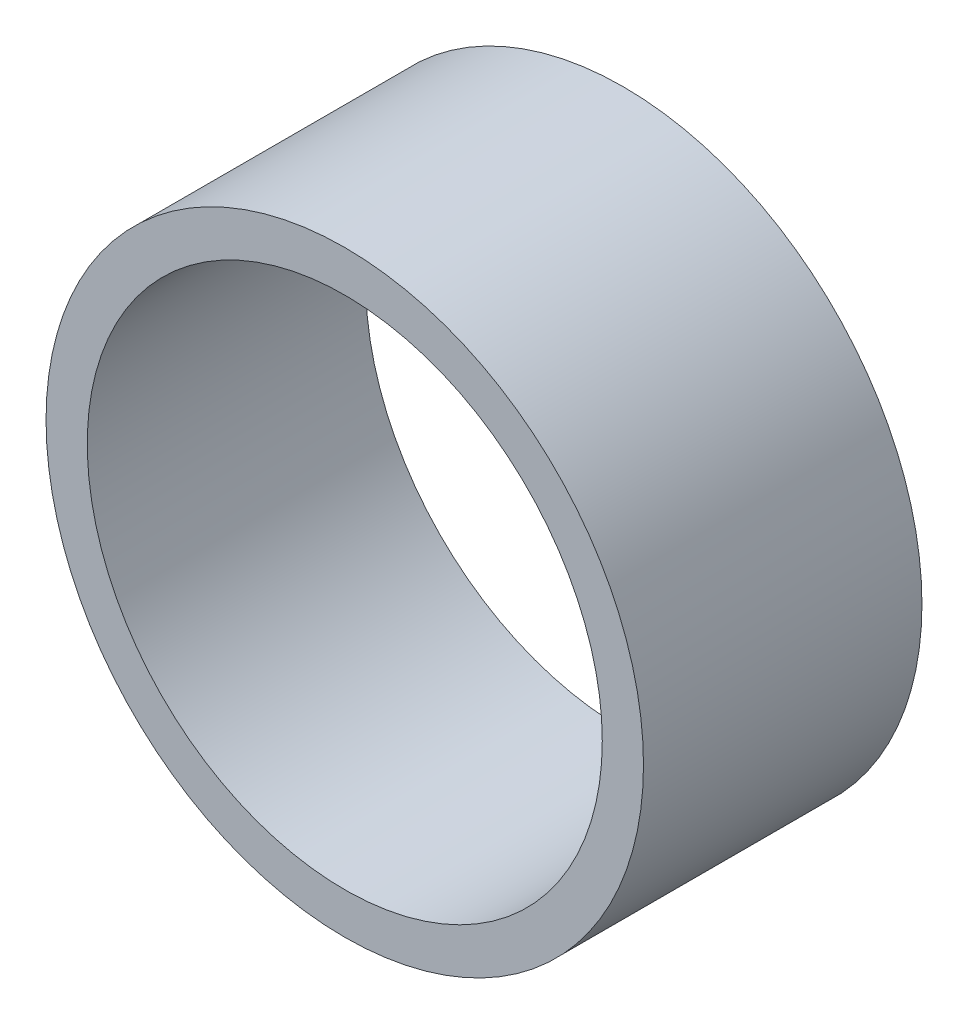
from build123d import *

# Parameters (mm, degrees)
SKETCH1_R           = 87
SKETCH1_R_2         = 75
BOSS_EXTRUDE1_DEPTH = 81.1


with BuildPart() as part:
    # Sketch1 → Boss-Extrude1 (new body)
    with BuildSketch(Plane.XY):
        Circle(SKETCH1_R)
        Circle(SKETCH1_R_2, mode=Mode.SUBTRACT)
    extrude(amount=BOSS_EXTRUDE1_DEPTH)


solid = part.part
